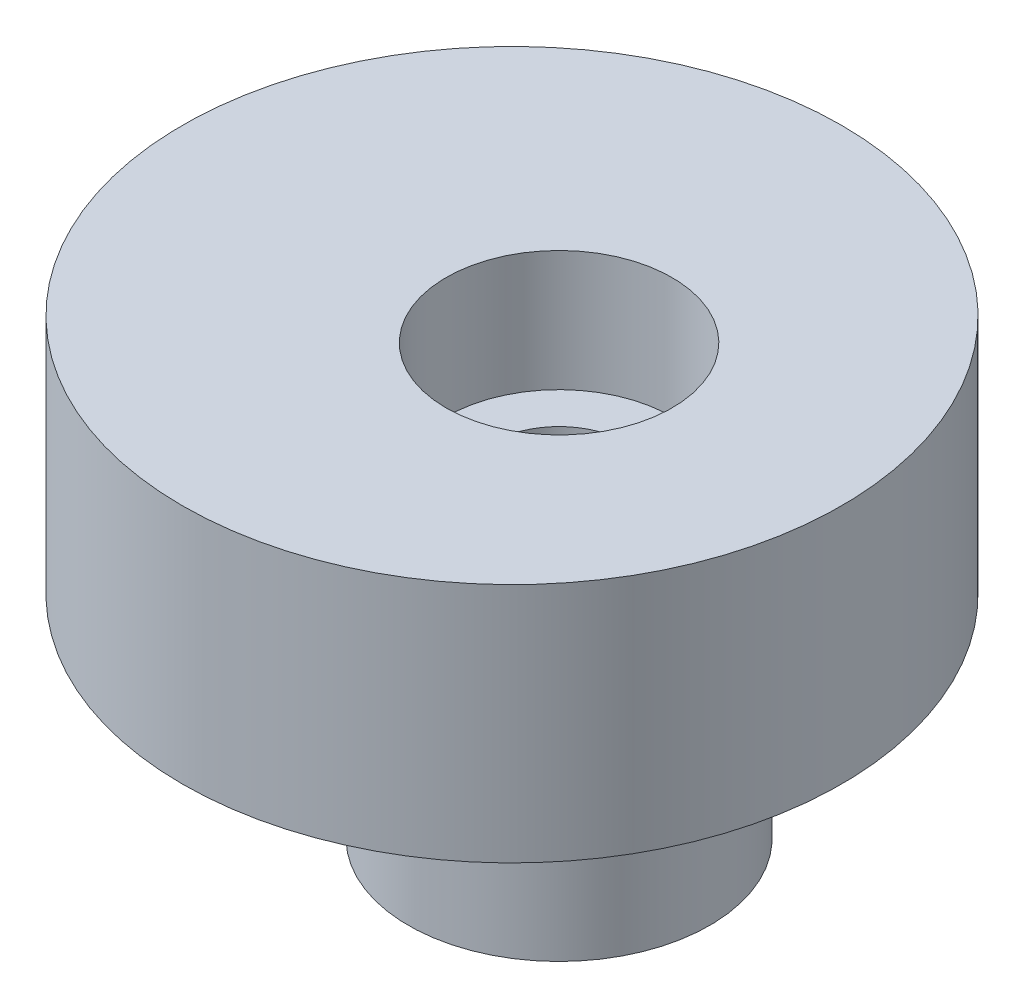
from build123d import *

# Parameters (mm, degrees)
SKETCH_1_R          = 8.75
SKETCH_1_R_2        = 1.8
EXTRUDE_1_DEPTH     = 6.4
SKETCH_7_R          = 3
CUT_EXTRUDE_1_DEPTH = 3.2
SKETCH_8_R          = 4
SKETCH_8_R_2        = 1.8
EXTRUDE_2_DEPTH     = 5
SKETCH_9_R          = 5.65
SKETCH_9_R_2        = 4
CUT_EXTRUDE_2_DEPTH = 2


with BuildPart() as part:
    # Эскиз1 → Бобышка-Вытянуть1 (new body)
    with BuildSketch(Plane(origin=(0, 0, 0), x_dir=(1, 0, 0), z_dir=(0, 1, 0))):
        with Locations((-1.25, 0)):
            Circle(SKETCH_1_R)
        Circle(SKETCH_1_R_2, mode=Mode.SUBTRACT)
    extrude(amount=EXTRUDE_1_DEPTH)

    # Эскиз7 → Вырез-Вытянуть1 (cut)
    with BuildSketch(Plane(origin=(0, 6.4, 0), x_dir=(1, 0, 0), z_dir=(0, 1, 0))):
        Circle(SKETCH_7_R)
    extrude(amount=-CUT_EXTRUDE_1_DEPTH, mode=Mode.SUBTRACT)

    # Эскиз8 → Бобышка-Вытянуть2 (add)
    with BuildSketch(Plane.XZ):
        Circle(SKETCH_8_R)
        Circle(SKETCH_8_R_2, mode=Mode.SUBTRACT)
    extrude(amount=EXTRUDE_2_DEPTH)

    # Эскиз9 → Вырез-Вытянуть2 (cut)
    with BuildSketch(Plane.XZ):
        Circle(SKETCH_9_R)
        Circle(SKETCH_9_R_2, mode=Mode.SUBTRACT)
    extrude(amount=-CUT_EXTRUDE_2_DEPTH, mode=Mode.SUBTRACT)


solid = part.part
